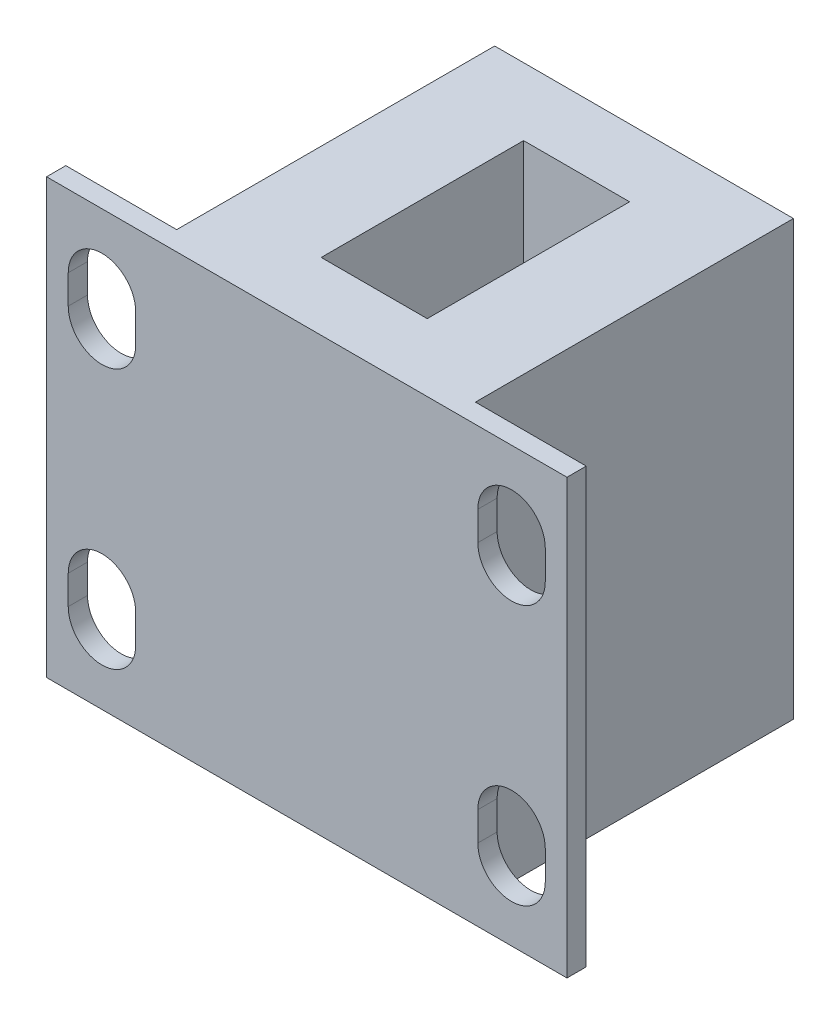
from build123d import *

# Parameters (mm, degrees)
SKETCH1_W            = 15.5
SKETCH1_H            = 17.5
SKETCH1_W_2          = 5.75
SKETCH1_H_2          = 1
BOSS_EXTRUDE1_DEPTH  = 22.5
CUT_EXTRUDE1_DEPTH   = 2
MIRROR2_COPY_1_DEPTH = 2
SKETCH3_W            = 5.5
SKETCH3_H            = 10.5
CUT_EXTRUDE2_DEPTH   = 10


with BuildPart() as part:
    # Sketch1 → Boss-Extrude1 (new body)
    with BuildSketch(Plane(origin=(0, 0, 0), x_dir=(1, 0, 0), z_dir=(0, 1, 0))):
        Rectangle(SKETCH1_W, SKETCH1_H)
        with Locations((10.625, -8.25)):
            Rectangle(SKETCH1_W_2, SKETCH1_H_2)
        with Locations((-10.625, -8.25)):
            Rectangle(SKETCH1_W_2, SKETCH1_H_2)
    extrude(amount=BOSS_EXTRUDE1_DEPTH)

    # Sketch2 → Cut-Extrude1 (cut, through all)
    with BuildSketch(Plane(origin=(0, 0, 7.75), x_dir=(-1, 0, 0), z_dir=(0, 0, -1))):
        with BuildLine():
            Line((12.375, 18.75), (12.375, 17.25))
            ThreePointArc((12.375, 17.25), (10.625, 15.5), (8.875, 17.25))
            Line((8.875, 17.25), (8.875, 18.75))
            ThreePointArc((8.875, 18.75), (10.625, 20.5), (12.375, 18.75))
        make_face()
    cut_extrude1 = extrude(amount=-CUT_EXTRUDE1_DEPTH, mode=Mode.SUBTRACT)

    # Mirror1: Cut-Extrude1 across plane
    add(cut_extrude1.mirror(Plane(origin=(0, 0, 0), x_dir=(0, 0, 1), z_dir=(1, 0, 0))), mode=Mode.SUBTRACT)

    # Mirror2: Cut-Extrude1 across plane
    add(cut_extrude1.mirror(Plane.ZX.offset(11.25)), mode=Mode.SUBTRACT)

    # Mirror2 copy 1 sketch → Mirror2 copy 1 (cut, through all)
    with BuildSketch(Plane(origin=(0, 22.5, 7.75), x_dir=(1, 0, 0), z_dir=(0, 0, -1))):
        with BuildLine():
            Line((12.375, 18.75), (12.375, 17.25))
            ThreePointArc((12.375, 17.25), (10.625, 15.5), (8.875, 17.25))
            Line((8.875, 17.25), (8.875, 18.75))
            ThreePointArc((8.875, 18.75), (10.625, 20.5), (12.375, 18.75))
        make_face()
    extrude(amount=-MIRROR2_COPY_1_DEPTH, mode=Mode.SUBTRACT)

    # Sketch3 → Cut-Extrude2 (cut)
    with BuildSketch(Plane(origin=(0, 22.5, 0), x_dir=(1, 0, 0), z_dir=(0, 1, 0))):
        Rectangle(SKETCH3_W, SKETCH3_H)
    extrude(amount=-CUT_EXTRUDE2_DEPTH, mode=Mode.SUBTRACT)


solid = part.part
